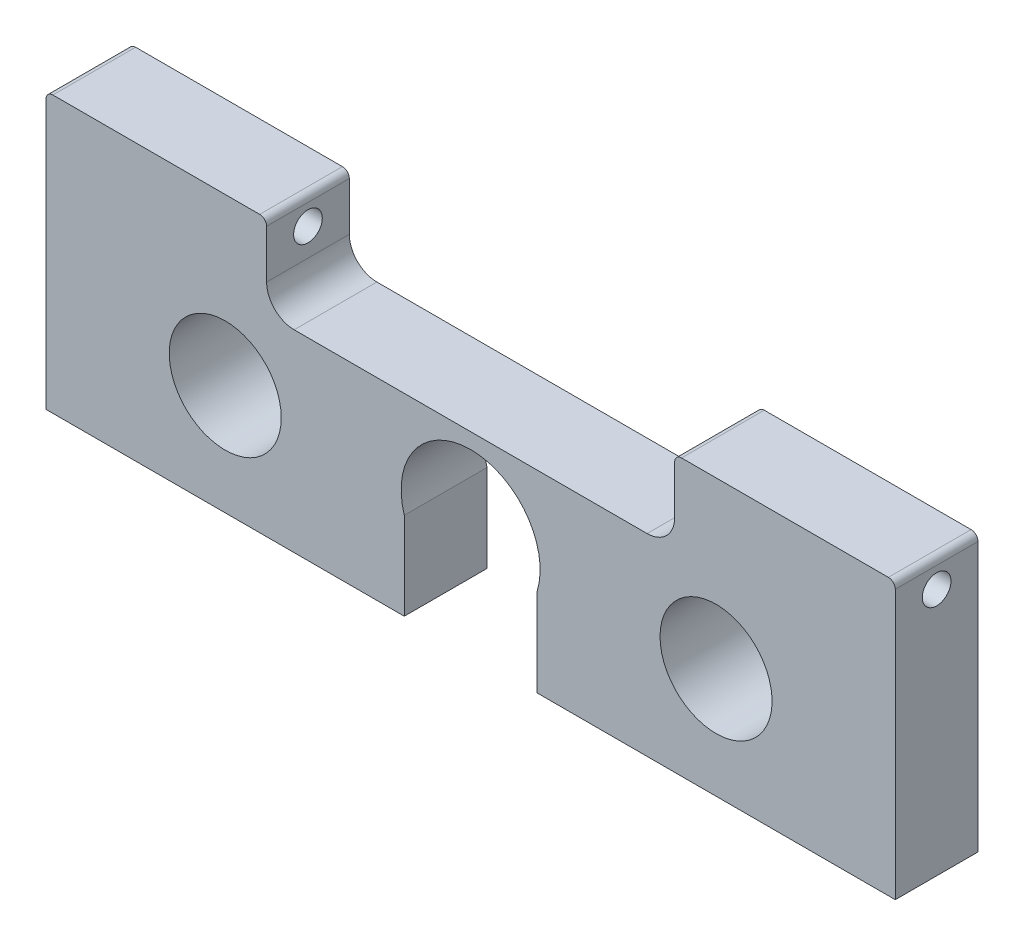
from build123d import *

# Parameters (mm, degrees)
SKETCH1_W               = 195.58
SKETCH1_H               = 38.1
BOSS_EXTRUDE1_DEPTH     = 19.05
SKETCH2_R               = 12.8984375
CUT_EXTRUDE1_DEPTH      = 20.05
CUT_EXTRUDE2_DEPTH      = 20.05
SKETCH4_W               = 19.05
SKETCH4_H               = 19.05
BOSS_EXTRUDE2_DEPTH     = 50.8
SKETCH6_R               = 3.302
CUT_EXTRUDE3_DEPTH      = 196.58
FILLET1_R               = 6.35
FILLET2_R               = 1.5875
SKETCH7_W               = 86.796683621
SKETCH7_H               = 6.35
BOSS_EXTRUDE3_DEPTH     = 19.05
SKETCH8_W               = 30.563761808
SKETCH8_H               = 20.145620364
CUT_EXTRUDE4_DEPTH      = 1
CUT_EXTRUDE4_DEPTH_BACK = 20.05


with BuildPart() as part:
    # Sketch1 → Boss-Extrude1 (new body)
    with BuildSketch(Plane.XY):
        Rectangle(SKETCH1_W, SKETCH1_H)
    extrude(amount=BOSS_EXTRUDE1_DEPTH)

    # Sketch2 → Cut-Extrude1 (cut, through all)
    with BuildSketch(Plane.XY.offset(19.05)):
        with Locations((-56.515, 0)):
            Circle(SKETCH2_R)
        with Locations((56.515, 0)):
            Circle(SKETCH2_R)
    extrude(amount=-CUT_EXTRUDE1_DEPTH, mode=Mode.SUBTRACT)

    # Sketch3 → Cut-Extrude2 (cut, through all)
    with BuildSketch(Plane.XY.offset(19.05)):
        with BuildLine():
            Line((-15.281880904, -5.254379636), (-10.086091047, -21.968397565))
            Line((-10.086091047, -21.968397565), (10.086091047, -21.968397565))
            Line((10.086091047, -21.968397565), (15.281880904, -5.254379636))
            ThreePointArc((15.281880904, -5.254379636), (0, 15.493999988), (-15.281880904, -5.254379636))
        make_face()
    extrude(amount=-CUT_EXTRUDE2_DEPTH, mode=Mode.SUBTRACT)

    # Sketch4 → Boss-Extrude2 (add)
    with BuildSketch(Plane.ZY.offset(97.79)):
        with Locations((9.525, 28.575)):
            Rectangle(SKETCH4_W, SKETCH4_H)
    boss_extrude2 = extrude(amount=-BOSS_EXTRUDE2_DEPTH)

    # Sketch6 → Cut-Extrude3 (cut, through all)
    with BuildSketch(Plane.ZY.offset(97.79)):
        with Locations((9.525, 31.75)):
            Circle(SKETCH6_R)
    cut_extrude3 = extrude(amount=-CUT_EXTRUDE3_DEPTH, mode=Mode.SUBTRACT)

    # Mirror2: Boss-Extrude2, Cut-Extrude3 across plane
    add(boss_extrude2.mirror(Plane(origin=(0, 0, 0), x_dir=(0, 0, 1), z_dir=(1, 0, 0))))
    add(cut_extrude3.mirror(Plane(origin=(0, 0, 0), x_dir=(0, 0, 1), z_dir=(1, 0, 0))), mode=Mode.SUBTRACT)

    # Fillet1
    fillet1_edges = [part.edges().sort_by_distance(p)[0] for p in [
        (-46.99, 19.05, 9.525),
        (46.99, 19.05, 9.525),
    ]]
    fillet(fillet1_edges, radius=FILLET1_R)

    # Fillet2
    fillet2_edges = [part.edges().sort_by_distance(p)[0] for p in [
        (-46.99, 38.1, 9.525),
        (-97.79, 38.1, 9.525),
        (97.79, 38.1, 9.525),
        (46.99, 38.1, 9.525),
    ]]
    fillet(fillet2_edges, radius=FILLET2_R)

    # Sketch7 → Boss-Extrude3 (add)
    with BuildSketch(Plane.XY.offset(19.05)):
        with Locations((-54.39165819, -22.225)):
            Rectangle(SKETCH7_W, SKETCH7_H)
        with Locations((54.39165819, -22.225)):
            Rectangle(SKETCH7_W, SKETCH7_H)
    extrude(amount=-BOSS_EXTRUDE3_DEPTH)

    # Sketch8 → Cut-Extrude4 (cut, two sides)
    with BuildSketch(Plane.XY.offset(19.05)) as cut_extrude4_sk:
        with Locations((0, -15.327189818)):
            Rectangle(SKETCH8_W, SKETCH8_H)
    extrude(amount=CUT_EXTRUDE4_DEPTH, mode=Mode.SUBTRACT)
    extrude(cut_extrude4_sk.sketch, amount=-CUT_EXTRUDE4_DEPTH_BACK, mode=Mode.SUBTRACT)


solid = part.part
